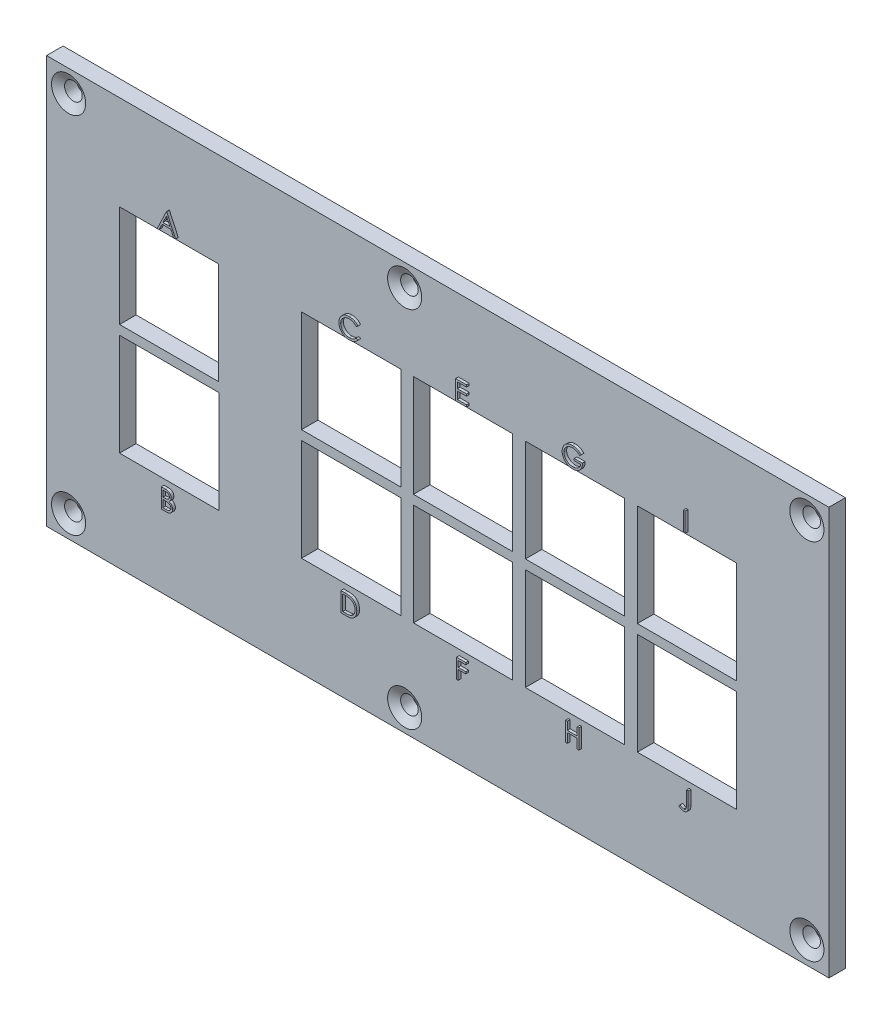
from build123d import *

# Parameters (mm, degrees)
ESQUISSE1_W             = 142
ESQUISSE1_H             = 74
BOSS_EXTRU_1_DEPTH      = 3
ESQUISSE2_R             = 1.6
ENL_V_MAT_EXTRU_1_DEPTH = 3
CHANFREIN1_SIZE         = 1.5
CHANFREIN1_SIZE2        = 0.866025404
ESQUISSE3_W             = 18.02
ESQUISSE3_H             = 18.526
ESQUISSE3_W_2           = 18
ESQUISSE3_H_2           = 18.5
ESQUISSE3_W_3           = 18.018
ESQUISSE3_H_3           = 18.53
ENL_V_MAT_EXTRU_2_DEPTH = 3
BOSS_EXTRU_2_DEPTH      = 0.5
BOSS_EXTRU_2_2_DEPTH    = 0.5
BOSS_EXTRU_2_3_DEPTH    = 0.5
BOSS_EXTRU_2_4_DEPTH    = 0.5
ESQUISSE4_W             = 0.314102564
ESQUISSE4_H             = 3.5
BOSS_EXTRU_2_5_DEPTH    = 0.5
BOSS_EXTRU_2_6_DEPTH    = 0.5
BOSS_EXTRU_2_7_DEPTH    = 0.5
BOSS_EXTRU_2_8_DEPTH    = 0.5
BOSS_EXTRU_2_9_DEPTH    = 0.5
BOSS_EXTRU_2_10_DEPTH   = 0.5


with BuildPart() as part:
    # Esquisse1 → Boss.-Extru.1 (new body)
    with BuildSketch(Plane.XY):
        with Locations((71, 37)):
            Rectangle(ESQUISSE1_W, ESQUISSE1_H)
    extrude(amount=BOSS_EXTRU_1_DEPTH)

    # Esquisse2 → Enlèv. mat.-Extru.1 (cut)
    with BuildSketch(Plane.XY.offset(3)):
        with Locations((4, 70)):
            Circle(ESQUISSE2_R)
        with Locations((65, 70)):
            Circle(ESQUISSE2_R)
        with Locations((138, 70)):
            Circle(ESQUISSE2_R)
        with Locations((138, 4)):
            Circle(ESQUISSE2_R)
        with Locations((65, 4)):
            Circle(ESQUISSE2_R)
        with Locations((4, 4)):
            Circle(ESQUISSE2_R)
    extrude(amount=-ENL_V_MAT_EXTRU_1_DEPTH, mode=Mode.SUBTRACT)

    # Chanfrein1
    chanfrein1_edges = [part.edges().sort_by_distance(p)[0] for p in [
        (2.4, 70, 3),
        (63.4, 70, 3),
        (136.4, 70, 3),
        (136.4, 4, 3),
        (63.4, 4, 3),
        (2.4, 4, 3),
    ]]
    chanfrein1_side = [part.faces().sort_by_distance(p)[0] for p in [
        (71.009226776, 37, 3),
    ]]
    chamfer(chanfrein1_edges, length=CHANFREIN1_SIZE, length2=CHANFREIN1_SIZE2, reference=chanfrein1_side[0])

    # Esquisse3 → Enlèv. mat.-Extru.2 (cut)
    with BuildSketch(Plane.XY.offset(3)):
        with Locations((75.598, 47.587)):
            Rectangle(ESQUISSE3_W, ESQUISSE3_H)
        with Locations((22.25, 47.6)):
            Rectangle(ESQUISSE3_W_2, ESQUISSE3_H_2)
        with Locations((55.278, 47.587)):
            Rectangle(ESQUISSE3_W, ESQUISSE3_H)
        with Locations((22.259, 27.392)):
            Rectangle(ESQUISSE3_W_3, ESQUISSE3_H_3)
        with Locations((95.918, 47.587)):
            Rectangle(ESQUISSE3_W, ESQUISSE3_H)
        with Locations((116.238, 47.587)):
            Rectangle(ESQUISSE3_W, ESQUISSE3_H)
        with Locations((75.598, 27.377)):
            Rectangle(ESQUISSE3_W, ESQUISSE3_H)
        with Locations((55.278, 27.377)):
            Rectangle(ESQUISSE3_W, ESQUISSE3_H)
        with Locations((95.918, 27.377)):
            Rectangle(ESQUISSE3_W, ESQUISSE3_H)
        with Locations((116.238, 27.377)):
            Rectangle(ESQUISSE3_W, ESQUISSE3_H)
    extrude(amount=-ENL_V_MAT_EXTRU_2_DEPTH, mode=Mode.SUBTRACT)


with BuildPart() as body_2:
    # Esquisse4 → Boss.-Extru.2 (new body)
    with BuildSketch(Plane.XY.offset(3)):
        Polygon((22.294871795, 60.85), (23.91025641, 57.35), (23.568810096, 57.35), (23.051382212, 58.471794872), (21.46474359, 58.471794872), (20.932592147, 57.35), (20.58974359, 57.35), (22.25, 60.85), align=None)
        Polygon((22.268930288, 60.167808494), (21.635116186, 58.830769231), (22.885917468, 58.830769231), align=None, mode=Mode.SUBTRACT)
    extrude(amount=BOSS_EXTRU_2_DEPTH)


with BuildPart() as body_3:
    # Esquisse4 → Boss.-Extru.2 2 (new body)
    with BuildSketch(Plane.XY.offset(3)):
        Polygon((74.745435897, 60.85), (76.719794872, 60.85), (76.719794872, 60.491025641), (75.059538462, 60.491025641), (75.059538462, 59.414102564), (76.719794872, 59.414102564), (76.719794872, 59.055128205), (75.059538462, 59.055128205), (75.059538462, 57.708974359), (76.719794872, 57.708974359), (76.719794872, 57.35), (74.745435897, 57.35), align=None)
    extrude(amount=BOSS_EXTRU_2_2_DEPTH)


with BuildPart() as body_4:
    # Esquisse4 → Boss.-Extru.2 3 (new body)
    with BuildSketch(Plane.XY.offset(3)):
        with BuildLine():
            Line((56.983128205, 60.207772436), (56.708288462, 59.997435897))
            add(Edge.make_bspline(
                [(56.708288462, 59.997435897), (56.688682573, 60.020801867), (56.649735126, 60.067218783), (56.587075924, 60.132398327), (56.521774281, 60.193463589), (56.45385516, 60.250705469), (56.38209604, 60.302122234), (56.308235242, 60.350393337), (56.231037196, 60.393661075), (56.124285462, 60.446124061), (55.984637613, 60.500870216), (55.808842774, 60.546773448), (55.625331676, 60.575994623), (55.500134076, 60.579159465), (55.436453526, 60.580769231)],
                knots=[0, 0, 0, 0, 9.1485e-05, 0.000181737, 0.000271024, 0.000359627, 0.000447979, 0.000535687, 0.000624217, 0.000713268, 0.000892422, 0.00107303, 0.001257466, 0.001448389, 0.001448389, 0.001448389, 0.001448389], degree=3))
            add(Edge.make_bspline(
                [(55.436453526, 60.580769231), (55.401370226, 60.580365268), (55.331529234, 60.579561092), (55.22788076, 60.568951967), (55.126167709, 60.554040757), (55.026456243, 60.531915434), (54.928873284, 60.503942815), (54.832780882, 60.470517401), (54.739570282, 60.429162561), (54.647952044, 60.383454301), (54.560172833, 60.331826856), (54.477117785, 60.275513504), (54.399089818, 60.215144408), (54.326027205, 60.150493302), (54.257855257, 60.081851341), (54.195067946, 60.008487), (54.137882536, 59.930634826), (54.085165511, 59.849321419), (54.037952778, 59.764783627), (53.998422898, 59.676708556), (53.963417776, 59.586604453), (53.935718533, 59.493453293), (53.913794017, 59.397910527), (53.898666353, 59.299719739), (53.888177882, 59.199086059), (53.887377705, 59.130876747), (53.886974359, 59.096494391)],
                knots=[0, 0, 0, 0, 0.000105206, 0.000209435, 0.000312261, 0.00041348, 0.000515565, 0.000616682, 0.000718413, 0.000821258, 0.000923708, 0.001023662, 0.001122111, 0.001219464, 0.00131614, 0.001412112, 0.001508869, 0.001605718, 0.001702691, 0.001799013, 0.001895107, 0.001992482, 0.002090281, 0.00218895, 0.002290387, 0.00239349, 0.00239349, 0.00239349, 0.00239349], degree=3))
            add(Edge.make_bspline(
                [(53.886974359, 59.096494391), (53.888236178, 59.044763071), (53.890713592, 58.943195486), (53.912761926, 58.794424876), (53.946267018, 58.651904202), (53.996482595, 58.51652436), (54.058401645, 58.386616002), (54.136642257, 58.264377148), (54.227258794, 58.147960584), (54.331533213, 58.040117636), (54.445939029, 57.941603911), (54.568686941, 57.854853329), (54.699471229, 57.782538447), (54.836847859, 57.7223625), (54.981873973, 57.676105772), (55.134288775, 57.643541649), (55.293760771, 57.622299468), (55.402730171, 57.62026578), (55.458188301, 57.619230769)],
                knots=[0, 0, 0, 0, 0.000155106, 0.000304531, 0.000450265, 0.000593548, 0.000736853, 0.000881182, 0.001028026, 0.001178769, 0.001330408, 0.001480379, 0.001628835, 0.001777978, 0.001929641, 0.002084627, 0.002245075, 0.00241136, 0.00241136, 0.00241136, 0.00241136], degree=3))
            add(Edge.make_bspline(
                [(55.458188301, 57.619230769), (55.51929099, 57.620919549), (55.639555699, 57.624243472), (55.815923726, 57.652402721), (55.984759491, 57.698060638), (56.146072078, 57.761958561), (56.299406724, 57.845023849), (56.445003384, 57.945721726), (56.582984955, 58.065010059), (56.665956237, 58.156093187), (56.708288462, 58.202564103)],
                knots=[0, 0, 0, 0, 0.00018322, 0.00036062, 0.000534275, 0.000707044, 0.000879893, 0.001056289, 0.001237208, 0.001425665, 0.001425665, 0.001425665, 0.001425665], degree=3))
            Line((56.708288462, 58.202564103), (56.983128205, 57.994330929))
            add(Edge.make_bspline(
                [(56.983128205, 57.994330929), (56.961010095, 57.965792478), (56.91687982, 57.908852271), (56.845421803, 57.828580562), (56.770144506, 57.753076526), (56.690488796, 57.682948905), (56.607371004, 57.616794439), (56.519298692, 57.556492608), (56.427429659, 57.501201724), (56.33207518, 57.450574799), (56.233336567, 57.405657552), (56.131332133, 57.367203784), (56.026501557, 57.334078895), (55.918840049, 57.306826958), (55.808124292, 57.285555874), (55.694753818, 57.271336199), (55.578483942, 57.261594285), (55.500042521, 57.260706369), (55.460291667, 57.26025641)],
                knots=[0, 0, 0, 0, 0.000108293, 0.000216068, 0.000322162, 0.000427957, 0.000534281, 0.00064066, 0.000747915, 0.000855806, 0.000964371, 0.001073102, 0.001182643, 0.001294024, 0.001406092, 0.001520624, 0.001636667, 0.001755891, 0.001755891, 0.001755891, 0.001755891], degree=3))
            add(Edge.make_bspline(
                [(55.460291667, 57.26025641), (55.422648, 57.260518403), (55.34821231, 57.261036461), (55.238313558, 57.269428628), (55.131323977, 57.280878365), (55.027549351, 57.298118496), (54.926423376, 57.318462836), (54.828862792, 57.345734093), (54.733907581, 57.376283259), (54.641939241, 57.412188246), (54.552879541, 57.452704429), (54.467015729, 57.498495987), (54.384387297, 57.549177852), (54.304181876, 57.603632863), (54.227584293, 57.663610164), (54.153930767, 57.728276799), (54.082808291, 57.79741481), (54.038805606, 57.847269663), (54.016681891, 57.872335737)],
                knots=[0, 0, 0, 0, 0.0001129, 0.000223246, 0.000330481, 0.000435603, 0.000538732, 0.000639764, 0.000739316, 0.000837878, 0.000935767, 0.001032686, 0.001129604, 0.00122645, 0.001323362, 0.001421241, 0.001520399, 0.001620667, 0.001620667, 0.001620667, 0.001620667], degree=3))
            add(Edge.make_bspline(
                [(54.016681891, 57.872335737), (53.981246248, 57.915876926), (53.910802771, 58.002433637), (53.820677087, 58.142719618), (53.743529532, 58.289187827), (53.681153611, 58.442607755), (53.632390878, 58.602635143), (53.598609683, 58.769350657), (53.576658078, 58.942598599), (53.57414779, 59.060435388), (53.572871795, 59.120332532)],
                knots=[0, 0, 0, 0, 0.000168306, 0.00033458, 0.000499224, 0.000664315, 0.00083066, 0.00100034, 0.001174094, 0.001353718, 0.001353718, 0.001353718, 0.001353718], degree=3))
            add(Edge.make_bspline(
                [(53.572871795, 59.120332532), (53.574426988, 59.183287986), (53.577486735, 59.30714891), (53.60348253, 59.488922863), (53.645301326, 59.663074262), (53.704698215, 59.829278007), (53.780003566, 59.988408287), (53.87303018, 60.139249492), (53.982697322, 60.282766292), (54.10814489, 60.416781043), (54.245712225, 60.539320396), (54.393031039, 60.647126599), (54.549812986, 60.736844115), (54.714330838, 60.811840278), (54.887816519, 60.869484741), (55.069899888, 60.909837928), (55.260238803, 60.934955044), (55.390101229, 60.938130252), (55.456084936, 60.93974359)],
                knots=[0, 0, 0, 0, 0.000188789, 0.000371431, 0.000549644, 0.000725278, 0.00089996, 0.001076844, 0.001255917, 0.001440951, 0.001626689, 0.001807878, 0.001987546, 0.002167657, 0.002349462, 0.002534866, 0.002726448, 0.002924344, 0.002924344, 0.002924344, 0.002924344], degree=3))
            add(Edge.make_bspline(
                [(55.456084936, 60.93974359), (55.496299408, 60.939261452), (55.575899905, 60.938307108), (55.693652558, 60.929000965), (55.808294884, 60.913487359), (55.919905867, 60.892371289), (56.029028483, 60.866163968), (56.134828724, 60.83202367), (56.23792741, 60.792987138), (56.337674319, 60.748028672), (56.433590869, 60.697561931), (56.525647187, 60.642146307), (56.613112046, 60.581850502), (56.696600894, 60.517187326), (56.774717106, 60.446788767), (56.849678584, 60.372591171), (56.918939662, 60.292457347), (56.961692857, 60.236052413), (56.983128205, 60.207772436)],
                knots=[0, 0, 0, 0, 0.000120626, 0.000238766, 0.000354085, 0.000467531, 0.000579423, 0.000690512, 0.000800803, 0.000910007, 0.001018518, 0.001125773, 0.001232152, 0.001337058, 0.001442329, 0.001547432, 0.001653292, 0.001759736, 0.001759736, 0.001759736, 0.001759736], degree=3))
        make_face()
    extrude(amount=BOSS_EXTRU_2_3_DEPTH)


with BuildPart() as body_5:
    # Esquisse4 → Boss.-Extru.2 4 (new body)
    with BuildSketch(Plane.XY.offset(3)):
        with BuildLine():
            Line((97.533384615, 60.252644231), (97.264153846, 59.997435897))
            add(Edge.make_bspline(
                [(97.264153846, 59.997435897), (97.215434958, 60.04326676), (97.119158911, 60.133835623), (96.962198669, 60.251346618), (96.798435035, 60.352012719), (96.628722538, 60.433918955), (96.457263984, 60.499271716), (96.286335208, 60.545799856), (96.117689506, 60.575472393), (96.005522288, 60.579020763), (95.950251603, 60.580769231)],
                knots=[0, 0, 0, 0, 0.000200536, 0.000396289, 0.000586999, 0.000776397, 0.000960787, 0.001136655, 0.001307246, 0.001472961, 0.001472961, 0.001472961, 0.001472961], degree=3))
            add(Edge.make_bspline(
                [(95.950251603, 60.580769231), (95.916336903, 60.580355625), (95.848595462, 60.579529486), (95.747973518, 60.568985271), (95.648406881, 60.553820406), (95.550083506, 60.531878529), (95.45281222, 60.504069469), (95.356931328, 60.469284006), (95.262261973, 60.428728762), (95.169695892, 60.381866288), (95.079955388, 60.330386442), (94.995198553, 60.273337901), (94.914885154, 60.212549111), (94.840524728, 60.146498132), (94.771689542, 60.075783266), (94.70674117, 60.00171996), (94.647963874, 59.922284742), (94.594872709, 59.838939116), (94.547511091, 59.753146926), (94.505702437, 59.665733937), (94.470605349, 59.576990082), (94.442835894, 59.486804005), (94.41992524, 59.395873415), (94.403807633, 59.303568694), (94.39472091, 59.209791009), (94.39314913, 59.14699375), (94.392358974, 59.115424679)],
                knots=[0, 0, 0, 0, 0.000101701, 0.000203139, 0.000303193, 0.000403728, 0.000505139, 0.000606491, 0.000709509, 0.000813922, 0.000917583, 0.001019673, 0.001120217, 0.001219549, 0.001317716, 0.001416124, 0.001514842, 0.00161384, 0.001712379, 0.001808658, 0.001904353, 0.001998376, 0.002091562, 0.002185504, 0.002279198, 0.002373914, 0.002373914, 0.002373914, 0.002373914], degree=3))
            add(Edge.make_bspline(
                [(94.392358974, 59.115424679), (94.393114693, 59.083153862), (94.394624066, 59.018700349), (94.404284385, 58.922506276), (94.422212626, 58.827740874), (94.446180334, 58.734092741), (94.47616115, 58.641401493), (94.513533816, 58.550068983), (94.557799417, 58.460098592), (94.609035969, 58.372300975), (94.665222172, 58.286777951), (94.728165253, 58.20621843), (94.795025837, 58.129549652), (94.868239736, 58.058473889), (94.945459279, 57.991089992), (95.028991555, 57.92925447), (95.117194015, 57.871776247), (95.210201227, 57.819379728), (95.307004009, 57.772571192), (95.406260763, 57.730947296), (95.508288578, 57.696667959), (95.612551268, 57.668729855), (95.71892454, 57.645829557), (95.827948342, 57.631097077), (95.938821051, 57.620406246), (96.013559683, 57.619624576), (96.051213141, 57.619230769)],
                knots=[0, 0, 0, 0, 9.6818e-05, 0.000193372, 0.000289633, 0.000385881, 0.000483216, 0.000581645, 0.00068167, 0.000783767, 0.00088644, 0.000988395, 0.001090231, 0.001191373, 0.001294266, 0.001397472, 0.001502873, 0.001609927, 0.001717482, 0.001825293, 0.001932604, 0.002040093, 0.002149, 0.002258763, 0.002369974, 0.002482889, 0.002482889, 0.002482889, 0.002482889], degree=3))
            add(Edge.make_bspline(
                [(96.051213141, 57.619230769), (96.096591488, 57.620179346), (96.185699246, 57.622042029), (96.316685688, 57.636542319), (96.442488759, 57.659189112), (96.562754962, 57.692355009), (96.677623983, 57.734658684), (96.787516924, 57.78565407), (96.891568583, 57.84729713), (96.990091756, 57.916870997), (97.080848942, 57.994385829), (97.162703066, 58.078030284), (97.234348555, 58.167398351), (97.296853254, 58.261963666), (97.348561909, 58.362508971), (97.391004704, 58.468541534), (97.423537996, 58.580109046), (97.43689297, 58.657200677), (97.443641026, 58.696153846)],
                knots=[0, 0, 0, 0, 0.000136106, 0.000267267, 0.000394882, 0.00051922, 0.000641, 0.000761758, 0.000882124, 0.001003321, 0.001123172, 0.001239687, 0.001353892, 0.00146629, 0.00157918, 0.001692449, 0.001808499, 0.001927028, 0.001927028, 0.001927028, 0.001927028], degree=3))
            Line((97.443641026, 58.696153846), (96.276974359, 58.696153846))
            Line((96.276974359, 58.696153846), (96.276974359, 59.055128205))
            Line((96.276974359, 59.055128205), (97.75774359, 59.055128205))
            add(Edge.make_bspline(
                [(97.75774359, 59.055128205), (97.756037741, 58.988220716), (97.752699088, 58.857270675), (97.729280172, 58.666300404), (97.69146366, 58.48592871), (97.639803348, 58.315965639), (97.572928068, 58.156652046), (97.491555539, 58.00782618), (97.394383418, 57.870449499), (97.284872977, 57.743400495), (97.161973019, 57.630071283), (97.029004399, 57.530465345), (96.885747431, 57.44656273), (96.732337623, 57.378302067), (96.56927719, 57.325028073), (96.39618881, 57.287256496), (96.213307209, 57.264626533), (96.087970532, 57.261735153), (96.023869391, 57.26025641)],
                knots=[0, 0, 0, 0, 0.000200697, 0.000392801, 0.000576238, 0.000752994, 0.000924878, 0.001093697, 0.001260784, 0.001428776, 0.001595974, 0.001761299, 0.001926279, 0.002092931, 0.002264096, 0.002439994, 0.002623661, 0.002815923, 0.002815923, 0.002815923, 0.002815923], degree=3))
            add(Edge.make_bspline(
                [(96.023869391, 57.26025641), (95.984359256, 57.260825531), (95.906432535, 57.261948022), (95.791341607, 57.269925369), (95.679423986, 57.282205946), (95.570695977, 57.300751069), (95.464757635, 57.323465723), (95.36213805, 57.352552442), (95.262446308, 57.386221141), (95.165528322, 57.424516815), (95.072263776, 57.468888472), (94.982237259, 57.518198111), (94.894951133, 57.572191472), (94.810999968, 57.631802318), (94.729946347, 57.696584778), (94.652312903, 57.766668697), (94.577665025, 57.841839816), (94.530904561, 57.895218826), (94.507342949, 57.922115385)],
                knots=[0, 0, 0, 0, 0.000118523, 0.000233765, 0.000345956, 0.000456148, 0.000564516, 0.000670839, 0.000775933, 0.000880089, 0.000983271, 0.001085557, 0.001187895, 0.001290998, 0.001394253, 0.001499002, 0.001604602, 0.001711853, 0.001711853, 0.001711853, 0.001711853], degree=3))
            add(Edge.make_bspline(
                [(94.507342949, 57.922115385), (94.473157017, 57.964786038), (94.405352604, 58.049419055), (94.318074448, 58.185018999), (94.243673045, 58.325420859), (94.183305223, 58.471015488), (94.136167136, 58.621666701), (94.102360883, 58.777181992), (94.082553594, 58.937761622), (94.079700057, 59.046426887), (94.07825641, 59.101402244)],
                knots=[0, 0, 0, 0, 0.00016394, 0.000325158, 0.000482912, 0.000640071, 0.000797293, 0.000955853, 0.00111691, 0.001281823, 0.001281823, 0.001281823, 0.001281823], degree=3))
            add(Edge.make_bspline(
                [(94.07825641, 59.101402244), (94.078788648, 59.142568496), (94.07984636, 59.224377804), (94.092671876, 59.345835111), (94.111073294, 59.465135803), (94.138120349, 59.58218236), (94.172216614, 59.697052951), (94.2147701, 59.809800915), (94.264314996, 59.920492787), (94.321900492, 60.028366655), (94.385984951, 60.131991068), (94.455535172, 60.230948871), (94.531538772, 60.323437936), (94.612754571, 60.410629584), (94.700151562, 60.491428431), (94.792910985, 60.566582542), (94.891104328, 60.636192728), (94.995040508, 60.699162562), (95.103168193, 60.755726183), (95.215228194, 60.805315395), (95.331186305, 60.84629871), (95.450173783, 60.88107249), (95.573091283, 60.90678763), (95.69904682, 60.925436376), (95.828696932, 60.938196975), (95.916332961, 60.939223231), (95.960768429, 60.93974359)],
                knots=[0, 0, 0, 0, 0.000123447, 0.000245326, 0.00036601, 0.000485407, 0.000605413, 0.000725221, 0.000846669, 0.000968994, 0.001091771, 0.00121199, 0.001331568, 0.001450618, 0.001569191, 0.001688326, 0.001808545, 0.001929991, 0.002052609, 0.002174413, 0.002297271, 0.002421315, 0.002546037, 0.002673651, 0.002803207, 0.002936466, 0.002936466, 0.002936466, 0.002936466], degree=3))
            add(Edge.make_bspline(
                [(95.960768429, 60.93974359), (95.997006673, 60.939164098), (96.068862852, 60.938015034), (96.175788584, 60.930050386), (96.281061599, 60.917426505), (96.384837989, 60.900199718), (96.486764355, 60.876736028), (96.58713106, 60.848657743), (96.686083597, 60.81596592), (96.783311846, 60.776977074), (96.879469562, 60.732723449), (96.975091402, 60.682910027), (97.069850648, 60.626685022), (97.16391163, 60.563881487), (97.257867488, 60.495578069), (97.35023213, 60.419821245), (97.443235074, 60.339598489), (97.503036888, 60.281916305), (97.533384615, 60.252644231)],
                knots=[0, 0, 0, 0, 0.00010871, 0.000215559, 0.000321482, 0.000426718, 0.00053098, 0.000635089, 0.000739295, 0.000843451, 0.000949174, 0.001056739, 0.001166761, 0.001279546, 0.001395941, 0.001515076, 0.00163782, 0.001764288, 0.001764288, 0.001764288, 0.001764288], degree=3))
        make_face()
    extrude(amount=BOSS_EXTRU_2_4_DEPTH)


with BuildPart() as body_6:
    # Esquisse4 → Boss.-Extru.2 5 (new body)
    with BuildSketch(Plane.XY.offset(3)):
        with Locations((116.238, 59.1)):
            Rectangle(ESQUISSE4_W, ESQUISSE4_H)
    extrude(amount=BOSS_EXTRU_2_5_DEPTH)


with BuildPart() as body_7:
    # Esquisse4 → Boss.-Extru.2 6 (new body)
    with BuildSketch(Plane.XY.offset(3)):
        with BuildLine():
            Line((21.316692308, 17.127), (21.999584936, 17.127))
            add(Edge.make_bspline(
                [(21.999584936, 17.127), (22.033013414, 17.12682425), (22.097806124, 17.126483602), (22.192025566, 17.12120047), (22.280274377, 17.113996801), (22.362578149, 17.102566708), (22.438898852, 17.088774931), (22.509466489, 17.072073115), (22.574056661, 17.052046501), (22.651169398, 17.02020022), (22.739090058, 16.972877051), (22.834288451, 16.902948486), (22.91569269, 16.817416023), (22.985879008, 16.720933368), (23.041680127, 16.614797596), (23.082049425, 16.501538407), (23.1076073, 16.382616665), (23.110235734, 16.300973487), (23.111564103, 16.25971234)],
                knots=[0, 0, 0, 0, 0.00010027, 0.000194349, 0.000283026, 0.000365821, 0.000443519, 0.000515622, 0.000583254, 0.00064614, 0.000765662, 0.000881909, 0.000998927, 0.001118415, 0.001238844, 0.00135727, 0.001478274, 0.001601912, 0.001601912, 0.001601912, 0.001601912], degree=3))
            add(Edge.make_bspline(
                [(23.111564103, 16.25971234), (23.110470884, 16.221059784), (23.108322607, 16.145103867), (23.087779847, 16.034009758), (23.055619179, 15.928258539), (23.01091393, 15.828236154), (22.952811934, 15.73620254), (22.883953615, 15.651415274), (22.800876812, 15.577464217), (22.738633573, 15.536121315), (22.707016827, 15.515120994)],
                knots=[0, 0, 0, 0, 0.000115857, 0.00022767, 0.000337672, 0.000446877, 0.000555233, 0.000663318, 0.000773539, 0.000887324, 0.000887324, 0.000887324, 0.000887324], degree=3))
            add(Edge.make_bspline(
                [(22.707016827, 15.515120994), (22.746777255, 15.499855995), (22.822848802, 15.47065027), (22.927534814, 15.419014806), (23.017729659, 15.362852696), (23.094126805, 15.301520846), (23.15946446, 15.235412035), (23.216517402, 15.163556921), (23.265198776, 15.085018163), (23.3069117, 15.000614627), (23.339460456, 14.911208159), (23.36383636, 14.817637383), (23.377803809, 14.720237828), (23.37979145, 14.653952448), (23.380794872, 14.620489583)],
                knots=[0, 0, 0, 0, 0.000127722, 0.000244363, 0.000349599, 0.000445847, 0.000537565, 0.000627901, 0.000720503, 0.000814257, 0.000909859, 0.001005428, 0.001103887, 0.001204268, 0.001204268, 0.001204268, 0.001204268], degree=3))
            add(Edge.make_bspline(
                [(23.380794872, 14.620489583), (23.379818026, 14.586322711), (23.377896054, 14.519098433), (23.363716082, 14.420343299), (23.339706975, 14.325968352), (23.306635829, 14.235363169), (23.263473514, 14.148703035), (23.21094555, 14.065889771), (23.148313986, 13.98775544), (23.078251117, 13.913431817), (22.998988972, 13.84660403), (22.913473217, 13.787088323), (22.820626897, 13.738142261), (22.721974903, 13.697026239), (22.616410587, 13.665619041), (22.504407979, 13.643646467), (22.386063678, 13.62884143), (22.304853926, 13.627624225), (22.263206731, 13.627)],
                knots=[0, 0, 0, 0, 0.000102481, 0.000201635, 0.000298562, 0.000394165, 0.000490425, 0.000588455, 0.000687769, 0.000790423, 0.000894381, 0.000998232, 0.001102369, 0.001208616, 0.001318415, 0.001432129, 0.001550749, 0.00167562, 0.00167562, 0.00167562, 0.00167562], degree=3))
            Line((22.263206731, 13.627), (21.316692308, 13.627))
            Line((21.316692308, 13.627), (21.316692308, 17.127))
        make_face()
        with BuildLine():
            Line((21.630794872, 16.768025641), (21.630794872, 15.646230769))
            Line((21.630794872, 15.646230769), (21.841832532, 15.646230769))
            add(Edge.make_bspline(
                [(21.841832532, 15.646230769), (21.872681327, 15.646630692), (21.932287487, 15.647403425), (22.018607383, 15.649616942), (22.098732401, 15.655814985), (22.172524234, 15.662011248), (22.239866678, 15.672085835), (22.30061054, 15.684077958), (22.355709137, 15.696760863), (22.419248682, 15.71833035), (22.491321631, 15.750208025), (22.568154735, 15.799679861), (22.635889205, 15.858604215), (22.693086392, 15.926595176), (22.739897863, 16.001461362), (22.772411578, 16.082008243), (22.794458862, 16.166228375), (22.796450394, 16.224046627), (22.797461538, 16.253402244)],
                knots=[0, 0, 0, 0, 9.2559e-05, 0.000178842, 0.000258967, 0.000333616, 0.000400942, 0.000463093, 0.000519379, 0.000570374, 0.000664201, 0.000755025, 0.000843472, 0.000932526, 0.001020669, 0.001107124, 0.001192318, 0.001280185, 0.001280185, 0.001280185, 0.001280185], degree=3))
            add(Edge.make_bspline(
                [(22.797461538, 16.253402244), (22.796935358, 16.272828015), (22.795903198, 16.310933787), (22.787449896, 16.366483141), (22.773082321, 16.418726894), (22.754628028, 16.468381004), (22.728839339, 16.513892854), (22.698475876, 16.55683605), (22.661790186, 16.595748169), (22.620032873, 16.632117667), (22.57202425, 16.664362195), (22.517792958, 16.692602958), (22.456605281, 16.715343735), (22.389492426, 16.735259887), (22.315421339, 16.749248181), (22.235246786, 16.760901569), (22.148312066, 16.766834311), (22.088166964, 16.767619673), (22.057076923, 16.768025641)],
                knots=[0, 0, 0, 0, 5.8261e-05, 0.000114285, 0.000168029, 0.000220632, 0.000272728, 0.000324483, 0.000378062, 0.000432741, 0.000490301, 0.000551137, 0.000615721, 0.000685833, 0.000760908, 0.00084162, 0.000928788, 0.00102206, 0.00102206, 0.00102206, 0.00102206], degree=3))
            Line((22.057076923, 16.768025641), (21.630794872, 16.768025641))
        make_face(mode=Mode.SUBTRACT)
        with BuildLine():
            Line((21.630794872, 15.28725641), (21.630794872, 13.985974359))
            Line((21.630794872, 13.985974359), (22.078110577, 13.985974359))
            add(Edge.make_bspline(
                [(22.078110577, 13.985974359), (22.110129503, 13.986358106), (22.171841761, 13.987097729), (22.260942992, 13.989512283), (22.343526095, 13.995004559), (22.419214231, 14.003650409), (22.488824684, 14.013028858), (22.551522387, 14.025640139), (22.60781558, 14.040089099), (22.673089888, 14.062423272), (22.746593396, 14.097119743), (22.825804253, 14.149433969), (22.896230471, 14.211757277), (22.95603573, 14.283888191), (23.005048718, 14.362319518), (23.040704174, 14.445464868), (23.06269503, 14.531950395), (23.0653572, 14.590917108), (23.066692308, 14.620489583)],
                knots=[0, 0, 0, 0, 9.6064e-05, 0.000185151, 0.000267373, 0.000344257, 0.000413665, 0.000478015, 0.000536005, 0.000587888, 0.000684801, 0.000778918, 0.000871787, 0.000965866, 0.001059062, 0.00114827, 0.001236355, 0.001324974, 0.001324974, 0.001324974, 0.001324974], degree=3))
            add(Edge.make_bspline(
                [(23.066692308, 14.620489583), (23.066416203, 14.638982924), (23.065868448, 14.675671306), (23.057607833, 14.729587125), (23.045593964, 14.781812998), (23.03006253, 14.832490739), (23.007443063, 14.880704115), (22.981036518, 14.927406674), (22.950075116, 14.972660154), (22.90183095, 15.029872407), (22.831658966, 15.09578942), (22.73195219, 15.160326923), (22.618579892, 15.21237473), (22.536352399, 15.234474206), (22.493875801, 15.245890224)],
                knots=[0, 0, 0, 0, 5.5429e-05, 0.000109963, 0.000163198, 0.000216191, 0.000268588, 0.000322593, 0.000377046, 0.000432793, 0.000546889, 0.000664343, 0.000787646, 0.000919405, 0.000919405, 0.000919405, 0.000919405], degree=3))
            add(Edge.make_bspline(
                [(22.493875801, 15.245890224), (22.476846705, 15.249345308), (22.439924113, 15.256836643), (22.379716533, 15.264744346), (22.310980664, 15.271789406), (22.233557787, 15.277000564), (22.147349945, 15.282387107), (22.052173027, 15.284481929), (21.948415712, 15.286981189), (21.87642334, 15.287162323), (21.839028045, 15.28725641)],
                knots=[0, 0, 0, 0, 5.2115e-05, 0.000112995, 0.000182062, 0.000259389, 0.000345767, 0.00044116, 0.000544948, 0.000657129, 0.000657129, 0.000657129, 0.000657129], degree=3))
            Line((21.839028045, 15.28725641), (21.630794872, 15.28725641))
        make_face(mode=Mode.SUBTRACT)
    extrude(amount=BOSS_EXTRU_2_6_DEPTH)


with BuildPart() as body_8:
    # Esquisse4 → Boss.-Extru.2 7 (new body)
    with BuildSketch(Plane.XY.offset(3)):
        with BuildLine():
            Line((53.931846154, 13.627), (53.931846154, 17.127))
            Line((53.931846154, 17.127), (54.638576923, 17.127))
            add(Edge.make_bspline(
                [(54.638576923, 17.127), (54.700045911, 17.12655743), (54.818803677, 17.125702387), (54.990416124, 17.120280996), (55.149199887, 17.11069053), (55.294632746, 17.096721004), (55.427113958, 17.07956797), (55.546272566, 17.058067566), (55.652724709, 17.032679396), (55.718194149, 17.011033945), (55.749153846, 17.000798077)],
                knots=[0, 0, 0, 0, 0.000184407, 0.000356273, 0.000515031, 0.000661537, 0.000794508, 0.000915664, 0.001024665, 0.001122454, 0.001122454, 0.001122454, 0.001122454], degree=3))
            add(Edge.make_bspline(
                [(55.749153846, 17.000798077), (55.789648585, 16.985367371), (55.869719778, 16.954855877), (55.9837269, 16.897299576), (56.091052263, 16.832086474), (56.192271408, 16.759130611), (56.285072235, 16.676366263), (56.373080131, 16.587309177), (56.452694855, 16.488720837), (56.525603151, 16.382645849), (56.591338811, 16.270333797), (56.648477968, 16.151998688), (56.695931962, 16.02824148), (56.735325188, 15.899406332), (56.766371646, 15.765209954), (56.787553578, 15.625496088), (56.801524567, 15.480816899), (56.802928619, 15.382642435), (56.803641026, 15.332829327)],
                knots=[0, 0, 0, 0, 0.000129935, 0.000256923, 0.000382457, 0.000506429, 0.000630624, 0.000755071, 0.000881654, 0.001010204, 0.001140916, 0.00127168, 0.001403968, 0.001538146, 0.001675568, 0.001816774, 0.001961818, 0.002111216, 0.002111216, 0.002111216, 0.002111216], degree=3))
            add(Edge.make_bspline(
                [(56.803641026, 15.332829327), (56.803012058, 15.289568088), (56.801772612, 15.204317299), (56.790643296, 15.078676404), (56.774466976, 14.956762833), (56.749422778, 14.839157132), (56.719020265, 14.724828915), (56.680056114, 14.61499667), (56.635420617, 14.508652861), (56.583370739, 14.407235385), (56.526229354, 14.311152013), (56.464907611, 14.220576485), (56.399470915, 14.136801263), (56.329295282, 14.059572651), (56.255287566, 13.989007072), (56.176963235, 13.924515057), (56.094120185, 13.867358502), (56.007129462, 13.815291394), (55.913453333, 13.769871038), (55.811317466, 13.731441029), (55.700286288, 13.699594413), (55.580632331, 13.673023517), (55.452148854, 13.651946215), (55.314709888, 13.637819822), (55.168526598, 13.62826689), (55.068147333, 13.627430496), (55.016481571, 13.627)],
                knots=[0, 0, 0, 0, 0.000129755, 0.000255696, 0.000378151, 0.000498469, 0.000616165, 0.000732801, 0.000847787, 0.000961923, 0.00107447, 0.001182981, 0.001289856, 0.001393094, 0.001495748, 0.001596383, 0.00169713, 0.001797413, 0.001900265, 0.002008995, 0.002124372, 0.002246504, 0.002376522, 0.002514729, 0.002660846, 0.00281582, 0.00281582, 0.00281582, 0.00281582], degree=3))
            Line((55.016481571, 13.627), (53.931846154, 13.627))
        make_face()
        with BuildLine():
            Line((54.245948718, 13.985974359), (54.647691506, 13.985974359))
            add(Edge.make_bspline(
                [(54.647691506, 13.985974359), (54.705419877, 13.986222455), (54.816452676, 13.986699636), (54.976110673, 13.990886839), (55.121990069, 13.997728776), (55.254111579, 14.007303854), (55.372400603, 14.019972469), (55.477104353, 14.034097372), (55.567879611, 14.051694823), (55.622809048, 14.067645782), (55.648192308, 14.075016827)],
                knots=[0, 0, 0, 0, 0.000173183, 0.000333094, 0.000479096, 0.000611272, 0.000730431, 0.000835931, 0.000928194, 0.001007458, 0.001007458, 0.001007458, 0.001007458], degree=3))
            add(Edge.make_bspline(
                [(55.648192308, 14.075016827), (55.68014067, 14.086268385), (55.743274308, 14.108502758), (55.834155393, 14.14906042), (55.918912398, 14.197102489), (55.999022423, 14.250504763), (56.073349079, 14.311150765), (56.142773195, 14.377721754), (56.207154996, 14.450556529), (56.265829304, 14.529564691), (56.318337608, 14.614254486), (56.363808838, 14.70379332), (56.403660369, 14.79720013), (56.434938962, 14.895909289), (56.459454546, 14.999038347), (56.476819234, 15.106594561), (56.487633958, 15.218557843), (56.488895406, 15.294709967), (56.489538462, 15.333530449)],
                knots=[0, 0, 0, 0, 0.000101593, 0.000200759, 0.000298073, 0.000393552, 0.000489254, 0.000585454, 0.000681817, 0.000780535, 0.000880346, 0.000980374, 0.001081551, 0.001184655, 0.001290601, 0.001399295, 0.001511268, 0.001627707, 0.001627707, 0.001627707, 0.001627707], degree=3))
            add(Edge.make_bspline(
                [(56.489538462, 15.333530449), (56.489025174, 15.374463929), (56.488016817, 15.454878113), (56.475342506, 15.572868809), (56.456820951, 15.686349459), (56.430037265, 15.795327655), (56.395906386, 15.900016007), (56.353311744, 15.999835517), (56.304645125, 16.095840386), (56.246741788, 16.185814752), (56.183326195, 16.270907861), (56.112948315, 16.348862776), (56.036726277, 16.419857077), (55.955491427, 16.484996389), (55.866954328, 16.541660065), (55.773200637, 16.592346746), (55.672854966, 16.635362638), (55.60304227, 16.6582415), (55.567563301, 16.66986859)],
                knots=[0, 0, 0, 0, 0.000122746, 0.000241136, 0.000355593, 0.000467485, 0.000577457, 0.000685538, 0.00079278, 0.000899951, 0.001006101, 0.00111085, 0.001214524, 0.001318328, 0.001422759, 0.001529413, 0.00163777, 0.001749741, 0.001749741, 0.001749741, 0.001749741], degree=3))
            add(Edge.make_bspline(
                [(55.567563301, 16.66986859), (55.538212155, 16.677985018), (55.475803565, 16.69524277), (55.373964101, 16.714068143), (55.259348951, 16.730672642), (55.13144925, 16.744730681), (54.990410791, 16.754818002), (54.836125103, 16.762389317), (54.668525498, 16.767495949), (54.552342965, 16.767844657), (54.492042468, 16.768025641)],
                knots=[0, 0, 0, 0, 9.1321e-05, 0.000194173, 0.000310382, 0.000438754, 0.000580072, 0.000734511, 0.000902151, 0.001083046, 0.001083046, 0.001083046, 0.001083046], degree=3))
            Line((54.492042468, 16.768025641), (54.245948718, 16.768025641))
            Line((54.245948718, 16.768025641), (54.245948718, 13.985974359))
        make_face(mode=Mode.SUBTRACT)
    extrude(amount=BOSS_EXTRU_2_7_DEPTH)


with BuildPart() as body_9:
    # Esquisse4 → Boss.-Extru.2 8 (new body)
    with BuildSketch(Plane.XY.offset(3)):
        Polygon((74.880051282, 17.127), (76.585179487, 17.127), (76.585179487, 16.768025641), (75.194153846, 16.768025641), (75.194153846, 15.691102564), (76.585179487, 15.691102564), (76.585179487, 15.332128205), (75.194153846, 15.332128205), (75.194153846, 13.627), (74.880051282, 13.627), align=None)
    extrude(amount=BOSS_EXTRU_2_8_DEPTH)


with BuildPart() as body_10:
    # Esquisse4 → Boss.-Extru.2 9 (new body)
    with BuildSketch(Plane.XY.offset(3)):
        Polygon((94.706461538, 17.127), (95.020564103, 17.127), (95.020564103, 15.691102564), (96.815435897, 15.691102564), (96.815435897, 17.127), (97.129538462, 17.127), (97.129538462, 13.627), (96.815435897, 13.627), (96.815435897, 15.332128205), (95.020564103, 15.332128205), (95.020564103, 13.627), (94.706461538, 13.627), align=None)
    extrude(amount=BOSS_EXTRU_2_9_DEPTH)


with BuildPart() as body_11:
    # Esquisse4 → Boss.-Extru.2 10 (new body)
    with BuildSketch(Plane.XY.offset(3)):
        with BuildLine():
            Line((116.641846154, 17.127), (116.955948718, 17.127))
            Line((116.955948718, 17.127), (116.955948718, 14.763518429))
            add(Edge.make_bspline(
                [(116.955948718, 14.763518429), (116.955634799, 14.719813259), (116.955032037, 14.635893997), (116.951717627, 14.515020102), (116.945584149, 14.404649415), (116.936649136, 14.304530968), (116.924728903, 14.214978413), (116.911087875, 14.135299795), (116.894575077, 14.066160113), (116.86970861, 13.988524757), (116.828934662, 13.903380952), (116.767567624, 13.811425802), (116.691334827, 13.730992391), (116.603033794, 13.661139666), (116.50189277, 13.605482435), (116.389994551, 13.565527257), (116.268027963, 13.5411564), (116.183428751, 13.538582495), (116.139842949, 13.53725641)],
                knots=[0, 0, 0, 0, 0.000131117, 0.000251761, 0.000362718, 0.000462694, 0.000553225, 0.000633683, 0.000705105, 0.0007663, 0.000877952, 0.000987044, 0.001096663, 0.001209011, 0.001323554, 0.00144132, 0.001564246, 0.001694883, 0.001694883, 0.001694883, 0.001694883], degree=3))
            add(Edge.make_bspline(
                [(116.139842949, 13.53725641), (116.10588459, 13.538337019), (116.037558124, 13.540511277), (115.935867416, 13.55823299), (115.83446544, 13.585549033), (115.732813991, 13.625551628), (115.62890475, 13.679957227), (115.521330403, 13.751142043), (115.408707212, 13.83897357), (115.334523926, 13.906011315), (115.295692308, 13.941102564)],
                knots=[0, 0, 0, 0, 0.000101817, 0.000204863, 0.000308785, 0.000416459, 0.000531862, 0.000660014, 0.000802922, 0.000959898, 0.000959898, 0.000959898, 0.000959898], degree=3))
            Line((115.295692308, 13.941102564), (115.480788462, 14.210333333))
            add(Edge.make_bspline(
                [(115.480788462, 14.210333333), (115.523491141, 14.180885937), (115.604119367, 14.125285413), (115.722623808, 14.053758813), (115.827620961, 13.992433647), (115.896303908, 13.961181368), (115.928104167, 13.946711538)],
                knots=[0, 0, 0, 0, 0.000155567, 0.000293731, 0.000415221, 0.00051997, 0.00051997, 0.00051997, 0.00051997], degree=3))
            add(Edge.make_bspline(
                [(115.928104167, 13.946711538), (115.947388478, 13.939152081), (115.985209307, 13.924326302), (116.043034387, 13.907780404), (116.100529424, 13.898737994), (116.138647118, 13.897056661), (116.157370994, 13.896230769)],
                knots=[0, 0, 0, 0, 6.212e-05, 0.00012183, 0.00018004, 0.000236239, 0.000236239, 0.000236239, 0.000236239], degree=3))
            add(Edge.make_bspline(
                [(116.157370994, 13.896230769), (116.181553782, 13.897253504), (116.229354238, 13.899275074), (116.298818232, 13.917124349), (116.365276264, 13.944368752), (116.426345921, 13.984260046), (116.482631308, 14.031691467), (116.529074134, 14.089047475), (116.567791378, 14.152613459), (116.591091072, 14.212784913), (116.605935844, 14.267661544), (116.615357471, 14.318094679), (116.623596131, 14.377056158), (116.630777683, 14.444616358), (116.634982153, 14.52091054), (116.639699426, 14.605714683), (116.641404687, 14.699242596), (116.641694508, 14.764453547), (116.641846154, 14.798574519)],
                knots=[0, 0, 0, 0, 7.2433e-05, 0.000143173, 0.000213879, 0.000287011, 0.000361082, 0.000433796, 0.000507383, 0.000583548, 0.000626408, 0.000677834, 0.000737327, 0.000804999, 0.000881578, 0.000966518, 0.001059791, 0.001162157, 0.001162157, 0.001162157, 0.001162157], degree=3))
            Line((116.641846154, 14.798574519), (116.641846154, 17.127))
        make_face()
    extrude(amount=BOSS_EXTRU_2_10_DEPTH)


solid = Compound([part.part, body_2.part, body_3.part, body_4.part, body_5.part, body_6.part, body_7.part, body_8.part, body_9.part, body_10.part, body_11.part])
